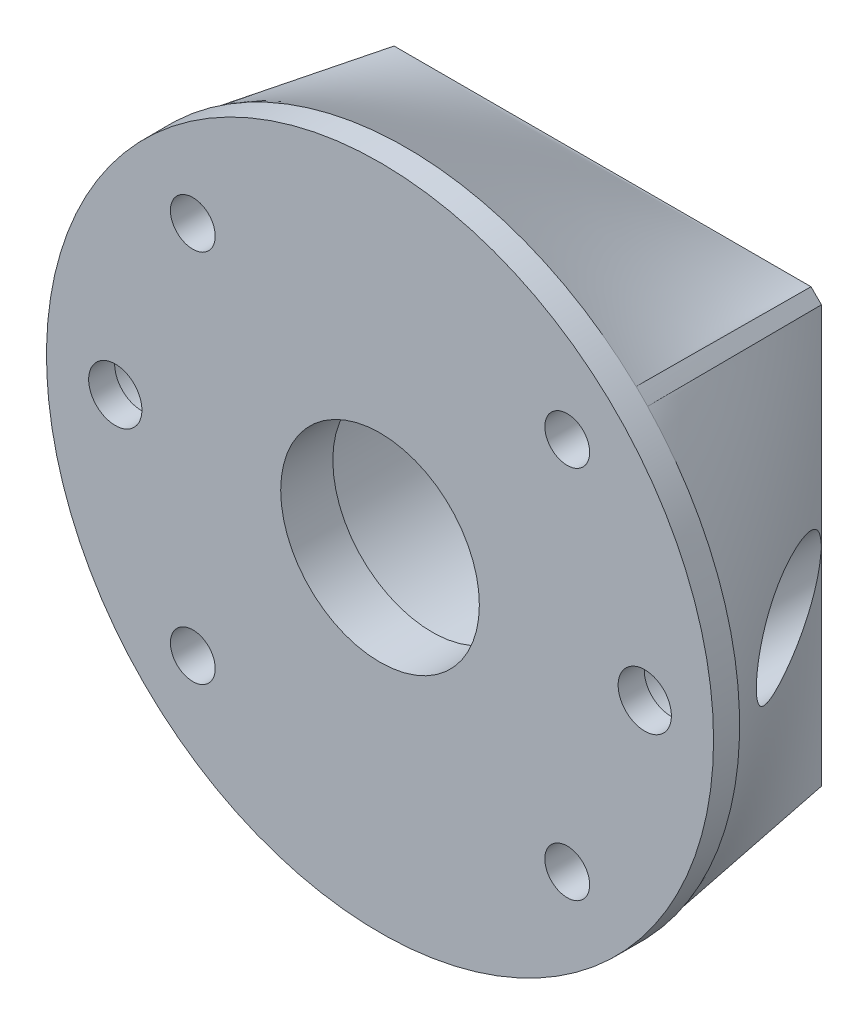
from build123d import *

# Parameters (mm, degrees)
SKETCH3_R           = 4.35
CUT_EXTRUDE1_DEPTH  = 19.35
SKETCH4_R           = 32
BOSS_EXTRUDE1_DEPTH = 2.5
SKETCH5_R           = 2.555
CUT_EXTRUDE2_DEPTH  = 40
SKETCH6_R           = 20.01
CUT_EXTRUDE3_DEPTH  = 3.7
SKETCH7_R           = 12.725
CUT_EXTRUDE4_DEPTH  = 16.35
SKETCH8_R           = 9.53
CUT_EXTRUDE5_DEPTH  = 16.35
SKETCH9_R           = 2.15
CUT_EXTRUDE6_DEPTH  = 30


with BuildPart() as part:
    # Sketch1 for Loft3 → Loft3 section 0
    with BuildSketch(Plane.XY):
        with BuildLine():
            # circular arc as an exact rational Bezier (weights 1, cos(half-angle), 1)
            Bezier((-22.068965517, 23.172413793), (-22.634146342, 22.634146342), (-23.172413793, 22.068965517), weights=[1, 0.999702691, 1])
            Bezier((-23.172413793, 22.068965517), (-44.190476191, 0), (-23.172413793, -22.068965517), weights=[1, 0.724137931, 1])
            Bezier((-23.172413793, -22.068965517), (-22.634146342, -22.634146342), (-22.068965517, -23.172413793), weights=[1, 0.999702691, 1])
            Bezier((-22.068965517, -23.172413793), (0, -44.190476191), (22.068965517, -23.172413793), weights=[1, 0.724137931, 1])
            Bezier((22.068965517, -23.172413793), (22.634146342, -22.634146342), (23.172413793, -22.068965517), weights=[1, 0.999702691, 1])
            Bezier((23.172413793, -22.068965517), (44.190476191, 0), (23.172413793, 22.068965517), weights=[1, 0.724137931, 1])
            Bezier((23.172413793, 22.068965517), (22.634146342, 22.634146342), (22.068965517, 23.172413793), weights=[1, 0.999702691, 1])
            Bezier((22.068965517, 23.172413793), (0, 44.190476191), (-22.068965517, 23.172413793), weights=[1, 0.724137931, 1])
        make_face()
    # Sketch2 → Loft3 section 1
    with BuildSketch(Plane(origin=(0, 0, -18.85), x_dir=(-1, 0, 0), z_dir=(0, 0, -1))):
        Polygon((20, 21), (21, 20), (21, -20), (20, -21), (-20, -21), (-21, -20), (-21, 20), (-20, 21), align=None)
    loft()

    # Sketch3 → Cut-Extrude1 (cut)
    with BuildSketch(Plane(origin=(0, 0, -18.85), x_dir=(-1, 0, 0), z_dir=(0, 0, -1))):
        with Locations((25.4, 0)):
            Circle(SKETCH3_R)
        with Locations((-25.4, 0)):
            Circle(SKETCH3_R)
    extrude(amount=-CUT_EXTRUDE1_DEPTH, mode=Mode.SUBTRACT)

    # Sketch4 → Boss-Extrude1 (add)
    with BuildSketch(Plane.XY):
        with Locations(Location((0, 0, 0), (0, 0, 136.397181012))):
            Circle(SKETCH4_R)
    extrude(amount=BOSS_EXTRUDE1_DEPTH)

    # Sketch5 → Cut-Extrude2 (cut)
    with BuildSketch(Plane(origin=(0, 0, -18.85), x_dir=(-1, 0, 0), z_dir=(0, 0, -1))):
        with Locations(Location((25.4, 0, 0), (0, 0, 180))):
            Circle(SKETCH5_R)
        with Locations(Location((-25.4, 0, 0), (0, 0, 180))):
            Circle(SKETCH5_R)
    extrude(amount=-CUT_EXTRUDE2_DEPTH, mode=Mode.SUBTRACT)

    # Sketch6 → Cut-Extrude3 (cut)
    with BuildSketch(Plane(origin=(0, 0, -18.85), x_dir=(-1, 0, 0), z_dir=(0, 0, -1))):
        Circle(SKETCH6_R)
    extrude(amount=-CUT_EXTRUDE3_DEPTH, mode=Mode.SUBTRACT)

    # Sketch7 → Cut-Extrude4 (cut)
    with BuildSketch(Plane(origin=(0, 0, -18.85), x_dir=(-1, 0, 0), z_dir=(0, 0, -1))):
        Circle(SKETCH7_R)
    extrude(amount=-CUT_EXTRUDE4_DEPTH, mode=Mode.SUBTRACT)

    # Sketch8 → Cut-Extrude5 (cut)
    with BuildSketch(Plane(origin=(0, 0, -2.5), x_dir=(-1, 0, 0), z_dir=(0, 0, -1))):
        Circle(SKETCH8_R)
    extrude(amount=-CUT_EXTRUDE5_DEPTH, mode=Mode.SUBTRACT)

    # Sketch9 → Cut-Extrude6 (cut)
    with BuildSketch(Plane(origin=(0, 0, -18.85), x_dir=(-1, 0, 0), z_dir=(0, 0, -1))):
        with Locations((-17.960512242, 17.960512242)):
            Circle(SKETCH9_R)
        with Locations(Location((17.960512242, 17.960512242, 0), (0, 0, 180))):
            Circle(SKETCH9_R)
        with Locations(Location((-17.960512242, -17.960512242, 0), (0, 0, 180))):
            Circle(SKETCH9_R)
        with Locations(Location((17.960512242, -17.960512242, 0), (0, 0, 180))):
            Circle(SKETCH9_R)
    extrude(amount=-CUT_EXTRUDE6_DEPTH, mode=Mode.SUBTRACT)


solid = part.part
